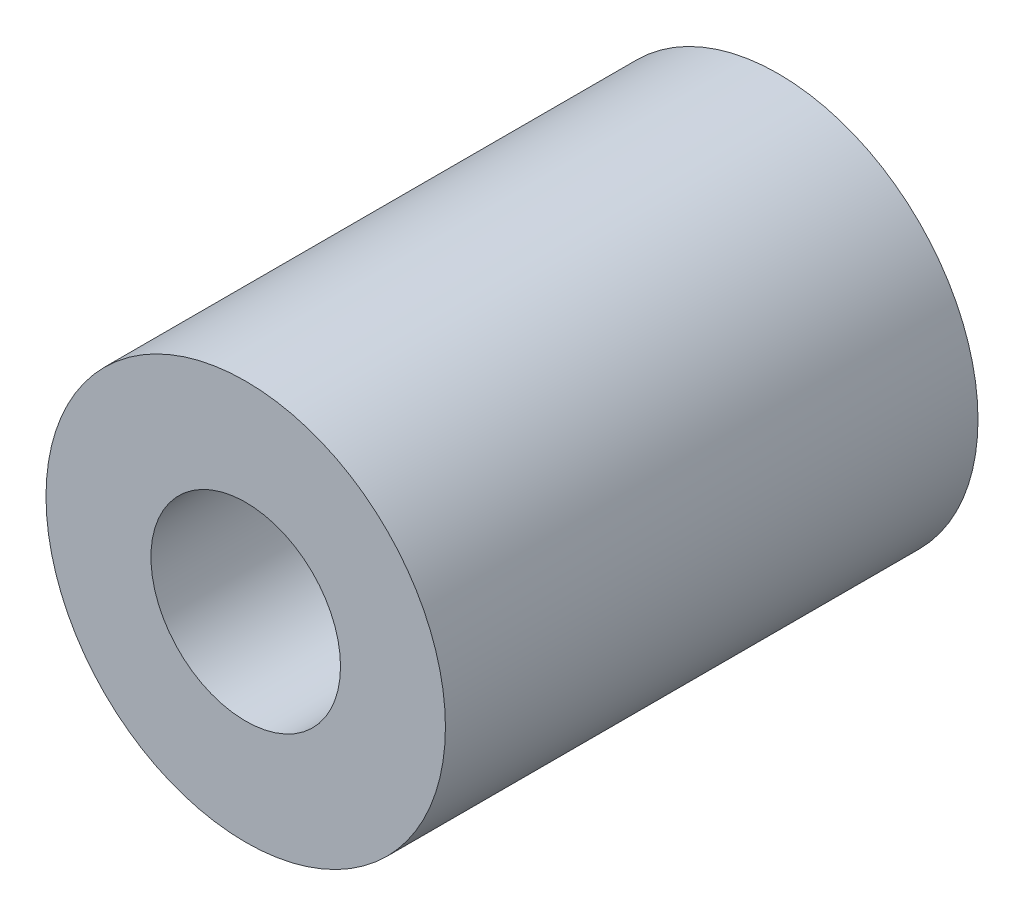
from build123d import *

# Parameters (mm, degrees)
SKETCH1_R             = 2.38125
BOSS_EXTRUDE1_DEPTH   = 6.35
F_4_40_TAPPED_HOLE1_D = 2.2606


with BuildPart() as part:
    # Sketch1 → Boss-Extrude1 (new body)
    with BuildSketch(Plane.XY):
        Circle(SKETCH1_R)
    extrude(amount=BOSS_EXTRUDE1_DEPTH)

    # #4-40 Tapped Hole1 (through all)
    with Locations(Plane.XY.offset(6.35)):
        with Locations((0, 0)):
            Hole(F_4_40_TAPPED_HOLE1_D / 2)


solid = part.part
